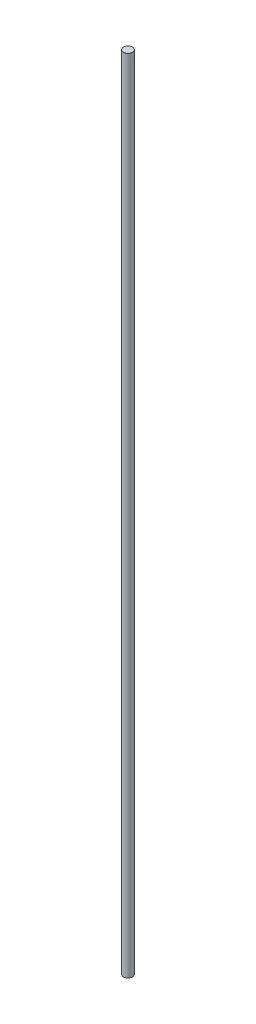
from build123d import *

# Parameters (mm, degrees)
SKETCH1_R           = 3.175
BOSS_EXTRUDE1_DEPTH = 558.8


with BuildPart() as part:
    # Sketch1 → Boss-Extrude1 (new body)
    with BuildSketch(Plane(origin=(0, 0, 0), x_dir=(1, 0, 0), z_dir=(0, 1, 0))):
        Circle(SKETCH1_R)
    extrude(amount=BOSS_EXTRUDE1_DEPTH)


solid = part.part
